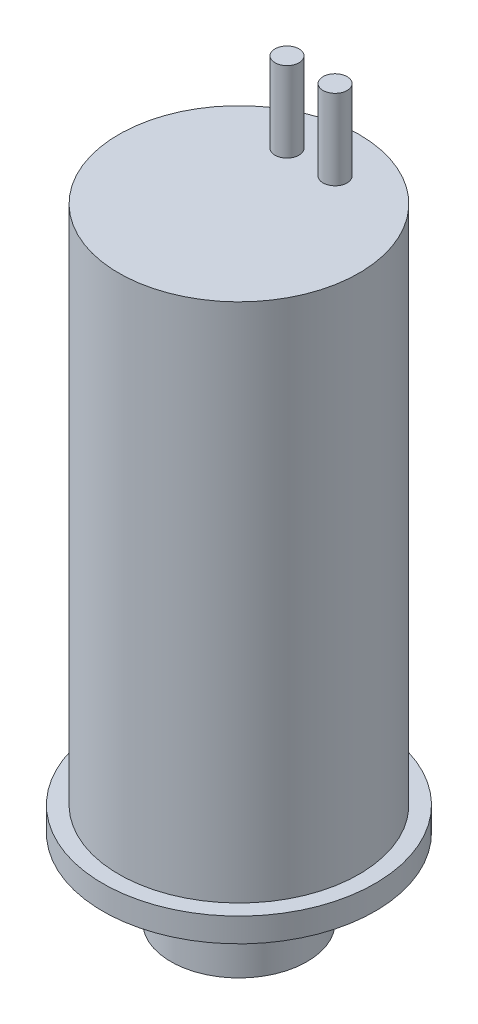
from build123d import *

# Parameters (mm, degrees)
SKETCH2_R           = 0.75
BOSS_EXTRUDE1_DEPTH = 5
SKETCH3_W           = 0.99
SKETCH3_H           = 0.65
SKETCH4_R           = 1.17
CUT_EXTRUDE1_DEPTH  = 7.5
SKETCH5_W           = 1.13
SKETCH5_H           = 0.9


with BuildPart() as part:
    # Sketch1 → Revolve2 (revolve)
    with BuildSketch(Plane.XY):
        Polygon((0, 0), (-4.25, 0), (-4.25, 5.5), (-8.5, 5.5), (-8.5, 7), (-7.5, 7), (-7.5, 39.5), (0, 39.5), align=None)
    revolve(axis=Axis((0, 0, 0), (0, 1, 0)))

    # Sketch2 → Boss-Extrude1 (add)
    with BuildSketch(Plane(origin=(0, 39.5, 0), x_dir=(1, 0, 0), z_dir=(0, 1, 0))):
        with Locations((1.5, 4.5)):
            Circle(SKETCH2_R)
        with Locations((-1.5, 4.5)):
            Circle(SKETCH2_R)
    extrude(amount=BOSS_EXTRUDE1_DEPTH)

    # Sketch3 → Cut-Revolve1 (revolve, cut)
    with BuildSketch(Plane(origin=(0, 0, 0), x_dir=(0, 0, -1), z_dir=(1, 0, 0))):
        with Locations((3.755, 0.325)):
            Rectangle(SKETCH3_W, SKETCH3_H)
    revolve(axis=Axis((0, 0, 0), (0, 1, 0)), mode=Mode.SUBTRACT)

    # Sketch4 → Cut-Extrude1 (cut)
    with BuildSketch(Plane.XZ):
        Circle(SKETCH4_R)
    extrude(amount=-CUT_EXTRUDE1_DEPTH, mode=Mode.SUBTRACT)

    # Sketch5 → Cut-Revolve2 (revolve, cut)
    with BuildSketch(Plane(origin=(0, 0, 0), x_dir=(0, 0, -1), z_dir=(1, 0, 0))):
        with Locations((7.065, 5.95)):
            Rectangle(SKETCH5_W, SKETCH5_H)
    revolve(axis=Axis((0, 0, 0), (0, 1, 0)), mode=Mode.SUBTRACT)


solid = part.part
